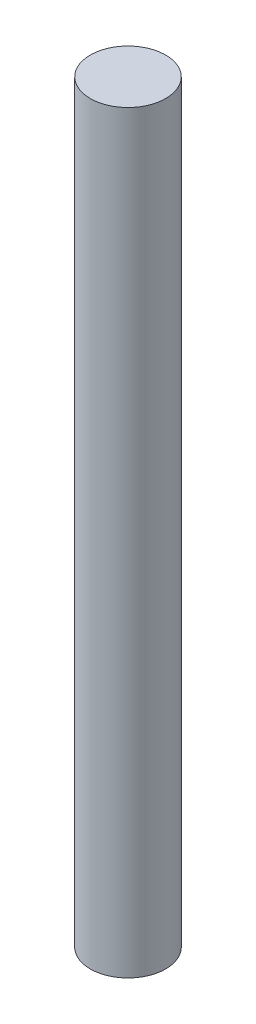
from build123d import *

# Parameters (mm, degrees)
SKETCH1_R           = 75
BOSS_EXTRUDE1_DEPTH = 1500


with BuildPart() as part:
    # Sketch1 → Boss-Extrude1 (new body)
    with BuildSketch(Plane(origin=(0, 0, 0), x_dir=(1, 0, 0), z_dir=(0, 1, 0))):
        Circle(SKETCH1_R)
    extrude(amount=BOSS_EXTRUDE1_DEPTH)


solid = part.part
